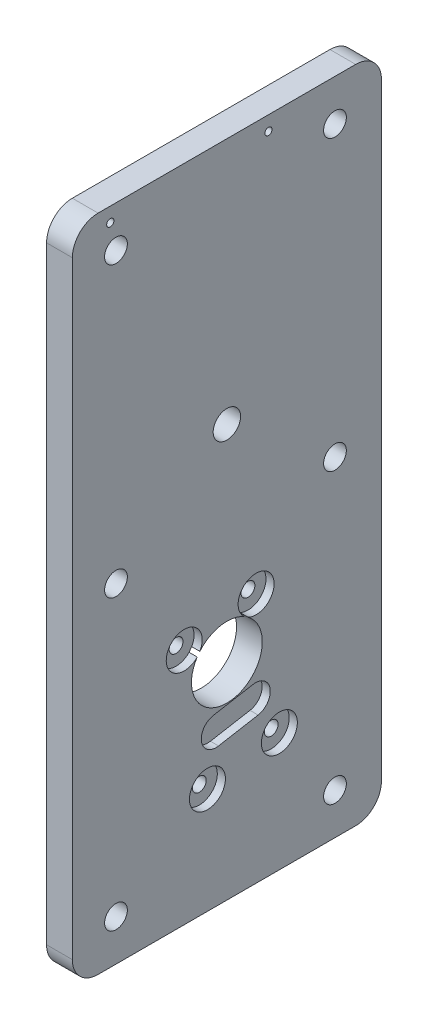
from build123d import *

# Parameters (mm, degrees)
SKETCH1_R                      = 8.73125
BOSS_EXTRUDE1_DEPTH            = 6.35
SKETCH7_R                      = 7.235
SKETCH7_R_2                    = 4.435
CUT_EXTRUDE2_DEPTH             = 2.000000064
M3_CLEARANCE_HOLE2_D           = 3.4
F_2_0_221_DIAMETER_HOLE1_D     = 5.6134
F_2_0_221_DIAMETER_HOLE1_DEPTH = 6.35
F_1_4_CLEARANCE_HOLE2_D        = 6.7564
TAP_DRILL_FOR_2_56_TAP2_D      = 1.778
TAP_DRILL_FOR_2_56_TAP2_DEPTH  = 12.7
TAP_DRILL_FOR_2_56_TAP2_TIP    = 0.53416509
FILLET1_R                      = 6.35
TAP_DRILL_FOR_2_56_TAP1_D      = 1.778


with BuildPart() as part:
    # Sketch1 → Boss-Extrude1 (new body)
    with BuildSketch(Plane(origin=(0, 0, 0), x_dir=(0, 0, -1), z_dir=(1, 0, 0))):
        with BuildLine():
            Line((34.282198326, -22.486920134), (34.282198326, 133.723079866))
            Line((34.282198326, 133.723079866), (-41.917801674, 133.723079866))
            Line((-41.917801674, 133.723079866), (-41.917801674, -22.486920134))
            ThreePointArc((-41.917801674, -22.486920134), (-40.057929734, -26.977048194), (-35.567801674, -28.836920134))
            Line((-35.567801674, -28.836920134), (27.932198326, -28.836920134))
            ThreePointArc((27.932198326, -28.836920134), (32.422326387, -26.977048194), (34.282198326, -22.486920134))
        make_face()
        with Locations((-3.817801674, 21.963079866)):
            Circle(SKETCH1_R, mode=Mode.SUBTRACT)
    extrude(amount=BOSS_EXTRUDE1_DEPTH)

    # Sketch7 → Cut-Extrude2 (cut)
    with BuildSketch(Plane(origin=(6.35, 0, 0), x_dir=(0, 0, -1), z_dir=(1, 0, 0))):
        with Locations((-3.817801674, 21.963079866)):
            Circle(SKETCH7_R)
        with Locations((3.388972242, 32.920368331)):
            Circle(SKETCH7_R_2)
        with Locations((-14.337567313, 29.794701133)):
            Circle(SKETCH7_R_2)
        with Locations((9.119362105, 0.421712482)):
            Circle(SKETCH7_R_2)
        with Locations((-8.60717745, -2.703954716)):
            Circle(SKETCH7_R_2)
        with BuildLine():
            Line((-7.135844138, 12.274719881), (2.613752617, 13.99383684))
            ThreePointArc((2.613752617, 13.99383684), (6.824739925, 11.045271784), (3.876174868, 6.834284476))
            Line((3.876174868, 6.834284476), (-5.873421887, 5.115167517))
            ThreePointArc((-5.873421887, 5.115167517), (-10.084409195, 8.063732573), (-7.135844138, 12.274719881))
        make_face()
    extrude(amount=-CUT_EXTRUDE2_DEPTH, mode=Mode.SUBTRACT)

    # M3 Clearance Hole2 (through all)
    with Locations(Plane(origin=(6.35, 0, 0), x_dir=(0, 0, -1), z_dir=(1, 0, 0))):
        with Locations((9.119362105, 0.421712482), (-8.60717745, -2.703954716), (-14.337567313, 29.794701133), (3.388972242, 32.920368331)):
            Hole(M3_CLEARANCE_HOLE2_D / 2)

    # #2 (0.221) Diameter Hole1
    with Locations(Plane.ZY):
        with Locations((-22.828731326, 123.563340866), (31.159813674, 123.563340866), (31.159813674, 52.443340866), (-22.828731326, 52.443340866), (-22.828731326, -18.676659134), (31.159813674, -18.676659134)):
            Hole(F_2_0_221_DIAMETER_HOLE1_D / 2, depth=F_2_0_221_DIAMETER_HOLE1_DEPTH)

    # 1/4 Clearance Hole2 (through all)
    with Locations(Plane(origin=(6.35, 0, 0), x_dir=(0, 0, -1), z_dir=(1, 0, 0))):
        with Locations((-3.817801674, 72.763079866)):
            Hole(F_1_4_CLEARANCE_HOLE2_D / 2)

    # Tap Drill for #2-56 Tap2
    with Locations(Plane(origin=(0, 167.140830498, -34.282198326), x_dir=(1, 0, 0), z_dir=(0, 0, -1))):
        with Locations((3.175, 58.817489631), (3.175, 79.137489631)):
            Hole(TAP_DRILL_FOR_2_56_TAP2_D / 2, depth=TAP_DRILL_FOR_2_56_TAP2_DEPTH)
            with Locations((0, 0, -(TAP_DRILL_FOR_2_56_TAP2_DEPTH + TAP_DRILL_FOR_2_56_TAP2_TIP / 2))):  # 118° drill point
                Cone(0, TAP_DRILL_FOR_2_56_TAP2_D / 2, TAP_DRILL_FOR_2_56_TAP2_TIP, mode=Mode.SUBTRACT)

    # Fillet1
    fillet1_edges = [part.edges().sort_by_distance(p)[0] for p in [
        (3.175, 133.723079866, 41.917801674),
        (3.175, 133.723079866, -34.282198326),
    ]]
    fillet(fillet1_edges, radius=FILLET1_R)

    # Tap Drill for #2-56 Tap1 (through all)
    with Locations(Plane(origin=(6.35, 0, 0), x_dir=(0, 0, -1), z_dir=(1, 0, 0))):
        with Locations((6.432198326, 130.157875406), (-32.567801674, 130.157875406)):
            Hole(TAP_DRILL_FOR_2_56_TAP1_D / 2)


solid = part.part
